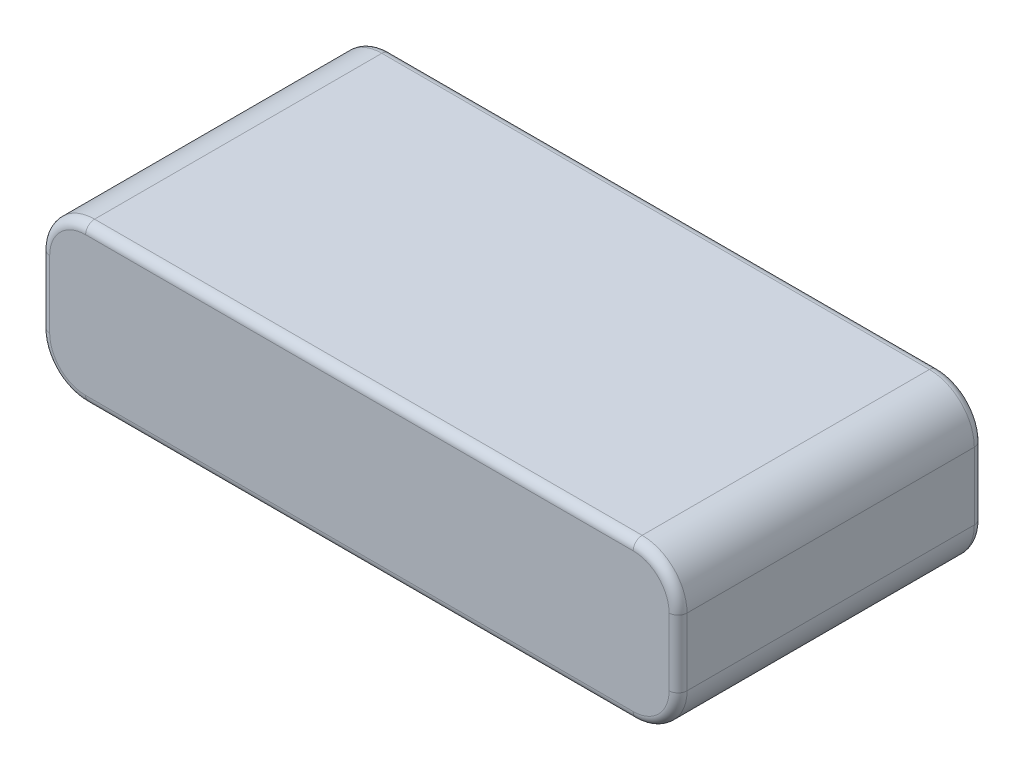
from build123d import *

# Parameters (mm, degrees)
SKETCH2_W           = 71
SKETCH2_H           = 34
BOSS_EXTRUDE1_DEPTH = 17.5
FILLET1_R           = 5
FILLET2_R           = 1


with BuildPart() as part:
    # Sketch2 → Boss-Extrude1 (new body)
    with BuildSketch(Plane(origin=(0, 0, 0), x_dir=(1, 0, 0), z_dir=(0, 1, 0))):
        Rectangle(SKETCH2_W, SKETCH2_H)
    extrude(amount=BOSS_EXTRUDE1_DEPTH)

    # Fillet1
    fillet1_edges = [part.edges().sort_by_distance(p)[0] for p in [
        (-35.5, 17.5, 0),
        (35.5, 17.5, 0),
        (-35.5, 0, 0),
        (35.5, 0, 0),
    ]]
    fillet(fillet1_edges, radius=FILLET1_R)

    # Fillet2
    fillet2_edges = [part.edges().sort_by_distance(p)[0] for p in [
        (0, 17.5, -17),
        (0, 17.5, 17),
        (0, 0, -17),
        (-35.5, 8.75, -17),
        (35.5, 8.75, -17),
        (-34.035533906, 16.035533906, -17),
        (-34.035533906, 1.464466094, -17),
        (34.035533906, 1.464466094, -17),
        (34.035533906, 16.035533906, -17),
        (35.5, 8.75, 17),
        (0, 0, 17),
        (-35.5, 8.75, 17),
        (-34.035533906, 16.035533906, 17),
        (-34.035533906, 1.464466094, 17),
        (34.035533906, 1.464466094, 17),
        (34.035533906, 16.035533906, 17),
    ]]
    fillet(fillet2_edges, radius=FILLET2_R)


solid = part.part
